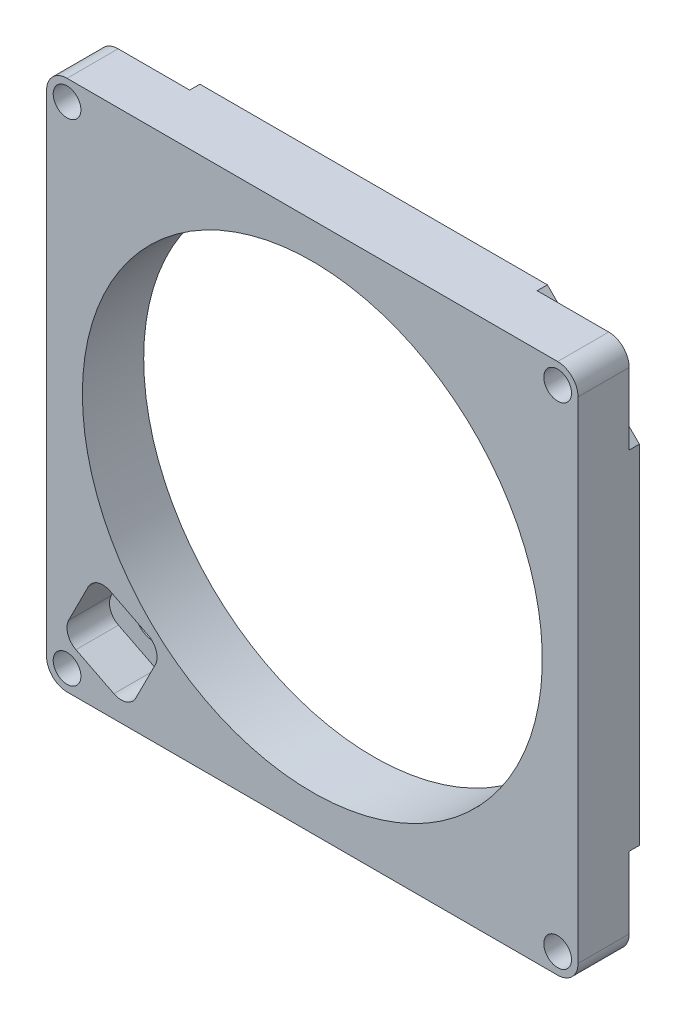
from build123d import *

# Parameters (mm, degrees)
BOSS_EXTRUDE1_DEPTH         = 7.9375
SKETCH2_R                   = 35.71875
BOSS_EXTRUDE2_DEPTH         = 1.5875
SKETCH3_R                   = 35.71875
CUT_EXTRUDE1_DEPTH          = 2.5875
CUT_EXTRUDE1_DEPTH_BACK     = 8.9375
F_6_CLEARANCE_HOLE1_D       = 4.3053
CUT_EXTRUDE2_DEPTH          = 6.604
F_0_257_DIAMETER_HOLE1_D    = 6.5278
F_51_0_067_DIAMETER_HOLE1_D = 1.7018


with BuildPart() as part:
    # Sketch1 → Boss-Extrude1 (new body)
    with BuildSketch(Plane.XY):
        with BuildLine():
            Line((-213.995000001, 2363.840725166), (-213.995000001, 2440.040725166))
            ThreePointArc((-213.995000001, 2440.040725166), (-214.92493597, 2442.285789196), (-217.170000001, 2443.215725166))
            Line((-217.170000001, 2443.215725166), (-293.370000001, 2443.215725166))
            ThreePointArc((-293.370000001, 2443.215725166), (-295.615064031, 2442.285789196), (-296.545000001, 2440.040725166))
            Line((-296.545000001, 2440.040725166), (-296.545000001, 2363.840725166))
            ThreePointArc((-296.545000001, 2363.840725166), (-295.615064031, 2361.595661136), (-293.370000001, 2360.665725166))
            Line((-293.370000001, 2360.665725166), (-217.170000001, 2360.665725166))
            ThreePointArc((-217.170000001, 2360.665725166), (-214.92493597, 2361.595661136), (-213.995000001, 2363.840725166))
        make_face()
    extrude(amount=-BOSS_EXTRUDE1_DEPTH)

    # Sketch2 → Boss-Extrude2 (add)
    with BuildSketch(Plane(origin=(0, 0, -7.9375), x_dir=(-1, 0, 0), z_dir=(0, 0, -1))):
        Polygon((282.257500001, 2360.665725166), (296.545000001, 2374.953225166), (296.545000001, 2428.928225166), (282.257500001, 2443.215725166), (228.282500001, 2443.215725166), (213.995000001, 2428.928225166), (213.995000001, 2374.953225166), (228.282500001, 2360.665725166), align=None)
        with Locations((255.270000001, 2401.940725166)):
            Circle(SKETCH2_R, mode=Mode.SUBTRACT)
    extrude(amount=BOSS_EXTRUDE2_DEPTH)

    # Sketch3 → Cut-Extrude1 (cut, two sides)
    with BuildSketch(Plane(origin=(0, 0, -7.9375), x_dir=(-1, 0, 0), z_dir=(0, 0, -1))) as cut_extrude1_sk:
        with Locations((255.270000001, 2401.940725166)):
            Circle(SKETCH3_R)
    extrude(amount=CUT_EXTRUDE1_DEPTH, mode=Mode.SUBTRACT)
    extrude(cut_extrude1_sk.sketch, amount=-CUT_EXTRUDE1_DEPTH_BACK, mode=Mode.SUBTRACT)

    # #6 Clearance Hole1 (through all)
    with Locations(Plane(origin=(0, 0, -7.9375), x_dir=(-1, 0, 0), z_dir=(0, 0, -1))):
        with Locations((217.170000001, 2440.040725166), (293.370000001, 2440.040725166), (293.370000001, 2363.840725166), (217.170000001, 2363.840725166)):
            Hole(F_6_CLEARANCE_HOLE1_D / 2)

    # Sketch6 → Cut-Extrude2 (cut)
    with BuildSketch(Plane.XY):
        with BuildLine():
            Line((-286.09833069, 2364.073109679), (-291.98898869, 2367.047457577))
            ThreePointArc((-291.98898869, 2367.047457577), (-293.256935443, 2368.521082635), (-293.111498919, 2370.459666654))
            Line((-293.111498919, 2370.459666654), (-290.083878389, 2376.455830423))
            ThreePointArc((-290.083878389, 2376.455830423), (-288.610253331, 2377.723777176), (-286.671669312, 2377.578340652))
            Line((-286.671669312, 2377.578340652), (-280.781011311, 2374.603992755))
            ThreePointArc((-280.781011311, 2374.603992755), (-279.513064558, 2373.130367697), (-279.658501082, 2371.191783678))
            Line((-279.658501082, 2371.191783678), (-282.686121613, 2365.195619909))
            ThreePointArc((-282.686121613, 2365.195619909), (-284.159746671, 2363.927673155), (-286.09833069, 2364.073109679))
        make_face()
    extrude(amount=-CUT_EXTRUDE2_DEPTH, mode=Mode.SUBTRACT)

    # F (0.257) Diameter Hole1 (through all)
    with Locations(Plane(origin=(0, 0, -9.525), x_dir=(-1, 0, 0), z_dir=(0, 0, -1))):
        with Locations((286.385000001, 2370.825725166)):
            Hole(F_0_257_DIAMETER_HOLE1_D / 2)

    # #51 (0.067) Diameter Hole1 (through all)
    with Locations(Plane(origin=(0, 0, -9.525), x_dir=(-1, 0, 0), z_dir=(0, 0, -1))):
        with Locations((290.619894526, 2373.004503404)):
            Hole(F_51_0_067_DIAMETER_HOLE1_D / 2)


solid = part.part
